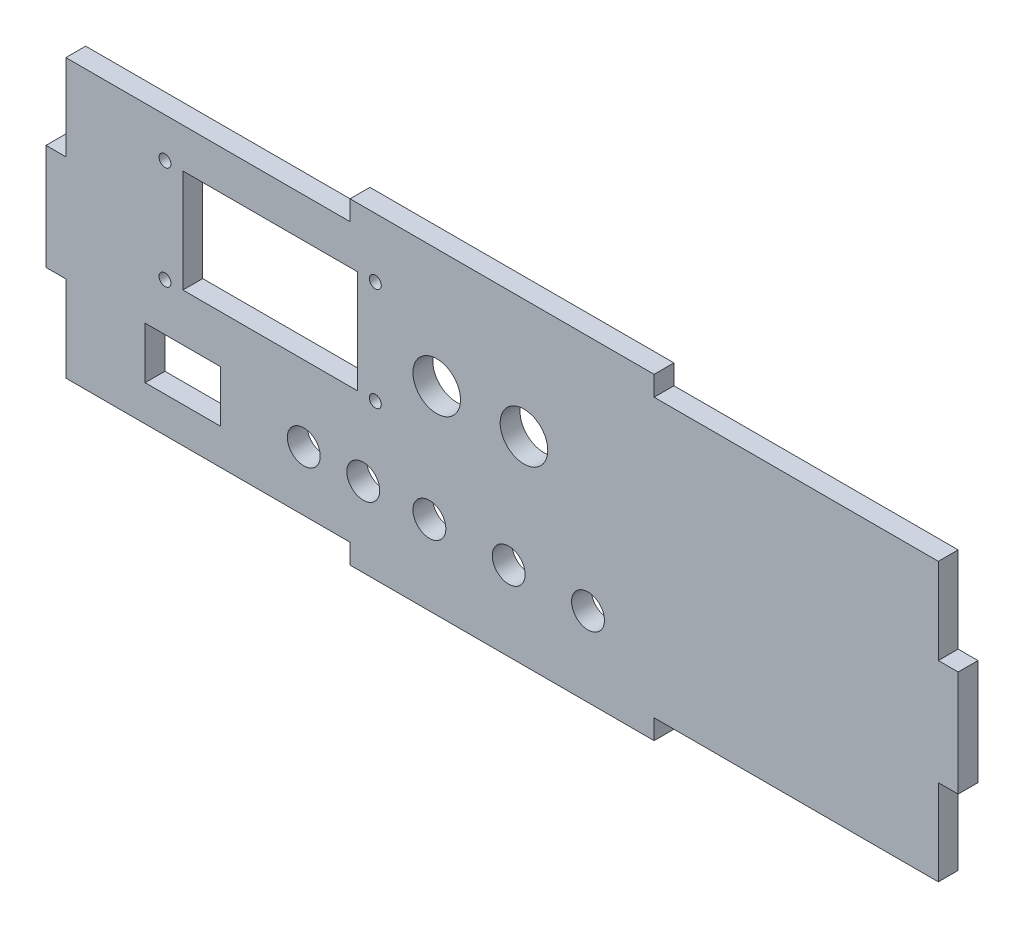
from build123d import *

# Parameters (mm, degrees)
CROQUIS1_R              = 1.5
CROQUIS1_W              = 44
CROQUIS1_H              = 26
CROQUIS1_W_2            = 5
CROQUIS1_H_2            = 26.666666666
CROQUIS1_W_3            = 76.666666666
CROQUIS1_H_3            = 5
SALIENTE_EXTRUIR1_DEPTH = 5
CROQUIS2_R              = 4.15
CORTAR_EXTRUIR1_DEPTH   = 10
CROQUIS3_W              = 19
CROQUIS3_H              = 13
CORTAR_EXTRUIR2_DEPTH   = 10
CROQUIS4_R              = 4.15
CORTAR_EXTRUIR3_DEPTH   = 10
CROQUIS5_R              = 6
CORTAR_EXTRUIR4_DEPTH   = 10


with BuildPart() as part:
    # Croquis1 → Saliente-Extruir1 (new body)
    with BuildSketch(Plane.XY):
        Polygon((5, 26.666666667), (5, 5), (76.666666667, 5), (153.333333333, 5), (225, 5), (225, 26.666666667), (225, 53.333333333), (225, 75), (153.333333333, 75), (76.666666667, 75), (5, 75), (5, 53.333333333), align=None)
        with Locations((30, 39)):
            Circle(CROQUIS1_R, mode=Mode.SUBTRACT)
        with Locations((83.04, 39)):
            Circle(CROQUIS1_R, mode=Mode.SUBTRACT)
        with Locations((56.52, 52)):
            Rectangle(CROQUIS1_W, CROQUIS1_H, mode=Mode.SUBTRACT)
        with Locations((30, 65)):
            Circle(CROQUIS1_R, mode=Mode.SUBTRACT)
        with Locations((83.04, 65)):
            Circle(CROQUIS1_R, mode=Mode.SUBTRACT)
        with Locations((227.5, 40)):
            Rectangle(CROQUIS1_W_2, CROQUIS1_H_2)
        with Locations((115, 2.5)):
            Rectangle(CROQUIS1_W_3, CROQUIS1_H_3)
        with Locations((2.5, 40)):
            Rectangle(CROQUIS1_W_2, CROQUIS1_H_2)
        with Locations((115, 77.5)):
            Rectangle(CROQUIS1_W_3, CROQUIS1_H_3)
    extrude(amount=SALIENTE_EXTRUIR1_DEPTH)

    # Croquis2 → Cortar-Extruir1 (cut)
    with BuildSketch(Plane.XY.offset(5)):
        with Locations((96.666666667, 20)):
            Circle(CROQUIS2_R)
        with Locations((116.666666667, 20)):
            Circle(CROQUIS2_R)
        with Locations((136.666666667, 20)):
            Circle(CROQUIS2_R)
    extrude(amount=-CORTAR_EXTRUIR1_DEPTH, mode=Mode.SUBTRACT)

    # Croquis3 → Cortar-Extruir2 (cut)
    with BuildSketch(Plane.XY.offset(5)):
        with Locations((34.5, 20.5)):
            Rectangle(CROQUIS3_W, CROQUIS3_H)
    extrude(amount=-CORTAR_EXTRUIR2_DEPTH, mode=Mode.SUBTRACT)

    # Croquis4 → Cortar-Extruir3 (cut)
    with BuildSketch(Plane.XY.offset(5)):
        with Locations((65, 20)):
            Circle(CROQUIS4_R)
        with Locations((80, 20)):
            Circle(CROQUIS4_R)
    extrude(amount=-CORTAR_EXTRUIR3_DEPTH, mode=Mode.SUBTRACT)

    # Croquis5 → Cortar-Extruir4 (cut)
    with BuildSketch(Plane.XY.offset(5)):
        with Locations((98.52, 50)):
            Circle(CROQUIS5_R)
        with Locations((120.52, 50)):
            Circle(CROQUIS5_R)
    extrude(amount=-CORTAR_EXTRUIR4_DEPTH, mode=Mode.SUBTRACT)


solid = part.part
